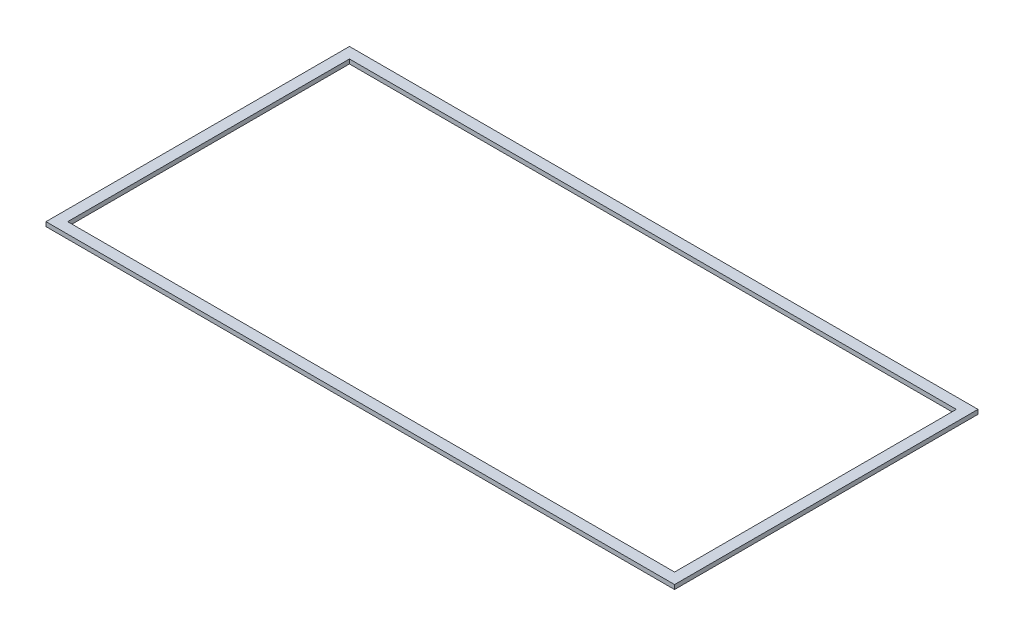
from build123d import *

# Parameters (mm, degrees)
SKETCH1_W           = 290
SKETCH1_H           = 140
SKETCH1_W_2         = 280
SKETCH1_H_2         = 130
BOSS_EXTRUDE1_DEPTH = 2


with BuildPart() as part:
    # Sketch1 → Boss-Extrude1 (new body)
    with BuildSketch(Plane(origin=(0, 0, 0), x_dir=(1, 0, 0), z_dir=(0, 1, 0))):
        Rectangle(SKETCH1_W, SKETCH1_H)
        Rectangle(SKETCH1_W_2, SKETCH1_H_2, mode=Mode.SUBTRACT)
    extrude(amount=BOSS_EXTRUDE1_DEPTH)


solid = part.part
